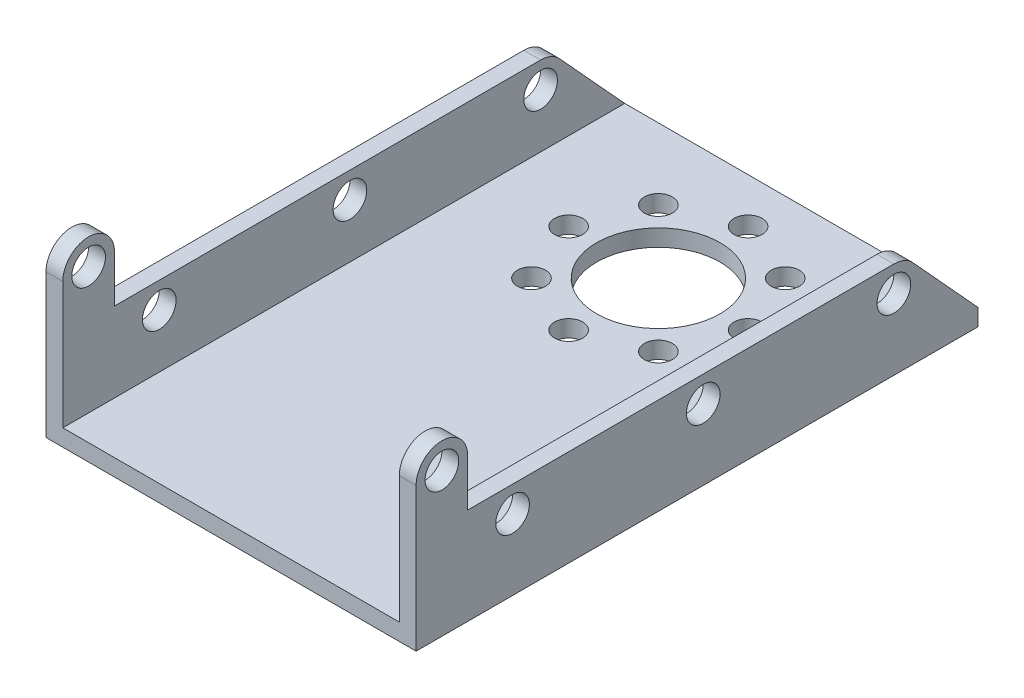
from build123d import *

# Parameters (mm, degrees)
SKETCH2_W           = 30
SKETCH2_H           = 50.1
SKETCH2_R           = 1.25
SKETCH2_R_2         = 5.5
BOSS_EXTRUDE1_DEPTH = 1.5
BOSS_EXTRUDE2_START = 15
SKETCH3_R           = 1.5
BOSS_EXTRUDE2_DEPTH = 1.5
BOSS_EXTRUDE3_START = -15
SKETCH3_2_R         = 1.5
BOSS_EXTRUDE3_DEPTH = 1.5


with BuildPart() as part:
    # Sketch2 → Boss-Extrude1 (new body)
    with BuildSketch(Plane(origin=(0, 0, 0), x_dir=(1, 0, 0), z_dir=(0, 1, 0))):
        with Locations((0, -0.55)):
            Rectangle(SKETCH2_W, SKETCH2_H)
        with Locations((-8, 12.5)):
            Circle(SKETCH2_R, mode=Mode.SUBTRACT)
        with Locations((-5.656854249, 18.156854249)):
            Circle(SKETCH2_R, mode=Mode.SUBTRACT)
        with Locations((0, 20.5)):
            Circle(SKETCH2_R, mode=Mode.SUBTRACT)
        with Locations((5.656854249, 18.156854249)):
            Circle(SKETCH2_R, mode=Mode.SUBTRACT)
        with Locations((8, 12.5)):
            Circle(SKETCH2_R, mode=Mode.SUBTRACT)
        with Locations((5.656854249, 6.843145751)):
            Circle(SKETCH2_R, mode=Mode.SUBTRACT)
        with Locations((0, 4.5)):
            Circle(SKETCH2_R, mode=Mode.SUBTRACT)
        with Locations((-5.656854249, 6.843145751)):
            Circle(SKETCH2_R, mode=Mode.SUBTRACT)
        with Locations((0, 12.5)):
            Circle(SKETCH2_R_2, mode=Mode.SUBTRACT)
    extrude(amount=BOSS_EXTRUDE1_DEPTH)

    # Sketch3 → Boss-Extrude2 (add)
    with BuildSketch(Plane(origin=(0, 0, 0), x_dir=(0, 0, -1), z_dir=(1, 0, 0)).offset(BOSS_EXTRUDE2_START)):
        with BuildLine():
            Line((24.5, 1.5), (18.69812916, 7.851243689))
            ThreePointArc((18.69812916, 7.851243689), (17.927938335, 8.404502374), (16.99999989, 8.6))
            Line((16.99999989, 8.6), (-21, 8.6))
            Line((-21, 8.6), (-21, 12.8))
            ThreePointArc((-21, 12.8), (-23.3, 15.1), (-25.6, 12.8))
            Line((-25.6, 12.8), (-25.6, 1.5))
            Line((-25.6, 1.5), (-25.6, 0))
            Line((-25.6, 0), (24.5, 0))
            Line((24.5, 0), (24.5, 1.5))
        make_face()
        with Locations((-23.3, 12.8)):
            Circle(SKETCH3_R, mode=Mode.SUBTRACT)
        with Locations((-17.00000011, 6.3)):
            Circle(SKETCH3_R, mode=Mode.SUBTRACT)
        with Locations((-1.1e-07, 6.3)):
            Circle(SKETCH3_R, mode=Mode.SUBTRACT)
        with Locations((16.99999989, 6.3)):
            Circle(SKETCH3_R, mode=Mode.SUBTRACT)
    extrude(amount=BOSS_EXTRUDE2_DEPTH)

    # Sketch3_2 → Boss-Extrude3 (add)
    with BuildSketch(Plane(origin=(0, 0, 0), x_dir=(0, 0, -1), z_dir=(1, 0, 0)).offset(BOSS_EXTRUDE3_START)):
        with BuildLine():
            Line((24.5, 1.5), (18.69812916, 7.851243689))
            ThreePointArc((18.69812916, 7.851243689), (17.927938335, 8.404502374), (16.99999989, 8.6))
            Line((16.99999989, 8.6), (-21, 8.6))
            Line((-21, 8.6), (-21, 12.8))
            ThreePointArc((-21, 12.8), (-23.3, 15.1), (-25.6, 12.8))
            Line((-25.6, 12.8), (-25.6, 1.5))
            Line((-25.6, 1.5), (-25.6, 0))
            Line((-25.6, 0), (24.5, 0))
            Line((24.5, 0), (24.5, 1.5))
        make_face()
        with Locations((-23.3, 12.8)):
            Circle(SKETCH3_2_R, mode=Mode.SUBTRACT)
        with Locations((-17.00000011, 6.3)):
            Circle(SKETCH3_2_R, mode=Mode.SUBTRACT)
        with Locations((-1.1e-07, 6.3)):
            Circle(SKETCH3_2_R, mode=Mode.SUBTRACT)
        with Locations((16.99999989, 6.3)):
            Circle(SKETCH3_2_R, mode=Mode.SUBTRACT)
    extrude(amount=-BOSS_EXTRUDE3_DEPTH)


solid = part.part
